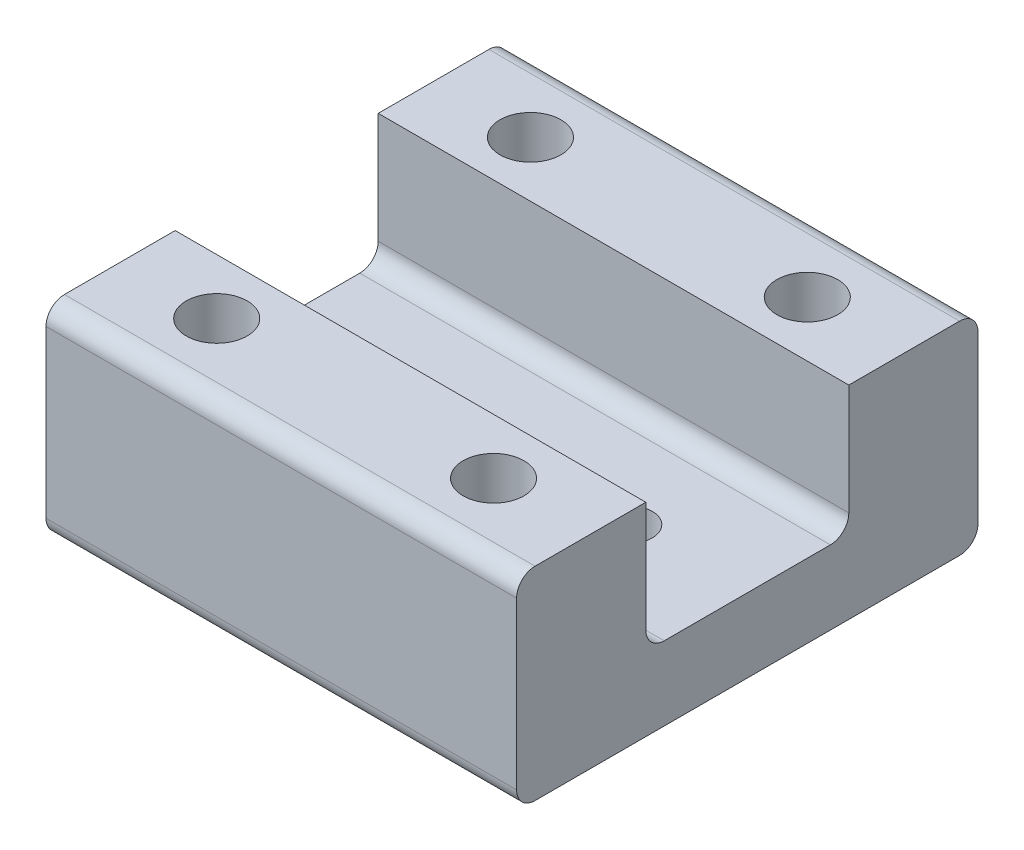
from build123d import *

# Parameters (mm, degrees)
SKETCH_1_W         = 25.5
SKETCH_1_H         = 25
EXTRUDE_1_DEPTH    = 4
SKETCH_6_W         = 25.5
SKETCH_6_H         = 7
EXTRUDE_2_DEPTH    = 7
HOLE_WIZARD_M3_1_D = 2.5
HOLE_WIZARD_M4_3_D = 3.3
FILLET_1_R         = 1


with BuildPart() as part:
    # 草图1 → 凸台-拉伸1 (new body)
    with BuildSketch(Plane(origin=(0, 0, 0), x_dir=(1, 0, 0), z_dir=(0, 1, 0))):
        Rectangle(SKETCH_1_W, SKETCH_1_H)
    extrude(amount=EXTRUDE_1_DEPTH)

    # 草图6 → 凸台-拉伸2 (add)
    with BuildSketch(Plane(origin=(0, 4, 0), x_dir=(1, 0, 0), z_dir=(0, 1, 0))):
        with Locations((0, 9)):
            Rectangle(SKETCH_6_W, SKETCH_6_H)
        with Locations((0, -9)):
            Rectangle(SKETCH_6_W, SKETCH_6_H)
    extrude(amount=EXTRUDE_2_DEPTH)

    # M3 螺纹孔1 (through all)
    with Locations(Plane(origin=(6.35, 0, 0), x_dir=(0, 0, -1), z_dir=(0, -1, 0))):
        with Locations((0, 0), (0, -12.7)):
            Hole(HOLE_WIZARD_M3_1_D / 2)

    # M4 螺纹孔3 (through all)
    with Locations(Plane(origin=(7.5, 0, 8.5), x_dir=(0, 0, -1), z_dir=(0, -1, 0))):
        with Locations((0, 0), (0, -15), (17, -15), (17, 0)):
            Hole(HOLE_WIZARD_M4_3_D / 2)

    # 圆角1
    fillet_1_edges = [part.edges().sort_by_distance(p)[0] for p in [
        (0, 4, -5.5),
        (0, 11, -12.5),
        (0, 4, 5.5),
        (0, 11, 12.5),
        (0, 0, 12.5),
        (0, 0, -12.5),
    ]]
    fillet(fillet_1_edges, radius=FILLET_1_R)


solid = part.part
